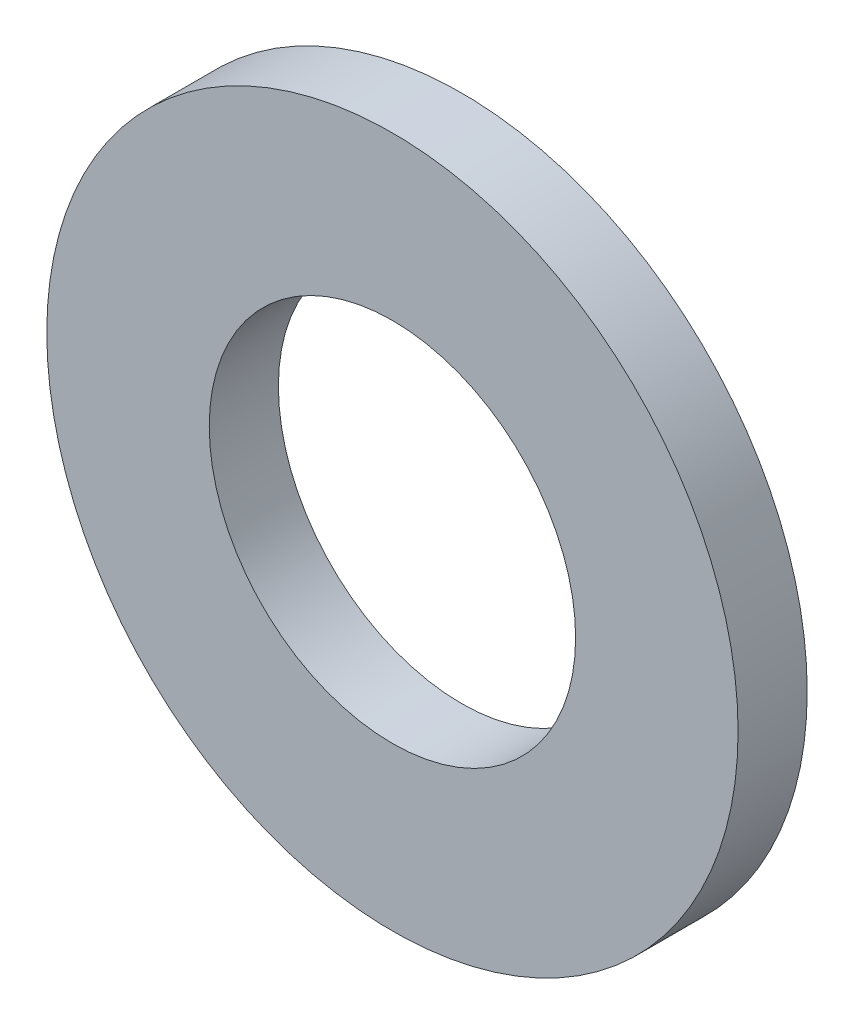
from build123d import *

# Parameters (mm, degrees)
SKETCH1_R          = 5
SKETCH1_R_2        = 2.65
BASE_EXTRUDE_DEPTH = 1


with BuildPart() as part:
    # Sketch1 → Base-Extrude (new body)
    with BuildSketch(Plane.XY):
        Circle(SKETCH1_R)
        Circle(SKETCH1_R_2, mode=Mode.SUBTRACT)
    extrude(amount=-BASE_EXTRUDE_DEPTH)


solid = part.part
